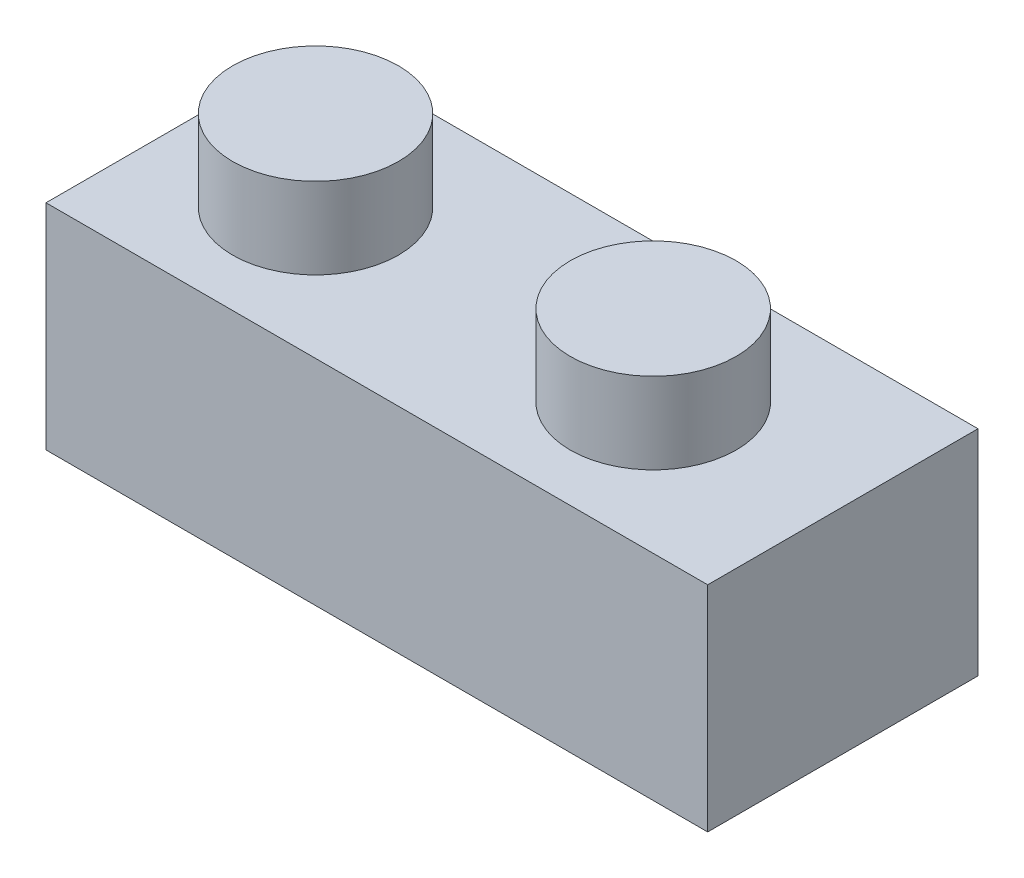
from build123d import *

# Parameters (mm, degrees)
ESQUISSE1_W             = 0.024479563
ESQUISSE1_H             = 0.007919518
BOSS_EXTRU_2_DEPTH      = 0.01
ENL_V_MAT_EXTRU_2_DEPTH = 0.007
ESQUISSE4_R             = 0.003068472
ESQUISSE4_R_2           = 0.003068475
BOSS_EXTRU_3_DEPTH      = 0.003
ESQUISSE5_R             = 0.001210602
BOSS_EXTRU_4_DEPTH      = 0.0065


with BuildPart() as part:
    # Esquisse1 → Boss.-Extru.2 (new body)
    with BuildSketch(Plane.XY):
        with Locations((0.012239782, 0.003959759)):
            Rectangle(ESQUISSE1_W, ESQUISSE1_H)
    extrude(amount=BOSS_EXTRU_2_DEPTH)

    # Esquisse3 → Enlèv. mat.-Extru.2 (cut)
    with BuildSketch(Plane(origin=(0, 0, 0), x_dir=(-1, 0, 0), z_dir=(0, -1, 0))):
        Polygon((-0.000784109, -0.009303073), (-0.023637888, -0.009504555), (-0.02371631, -0.000609239), (-0.000862531, -0.000407757), align=None)
    extrude(amount=-ENL_V_MAT_EXTRU_2_DEPTH, mode=Mode.SUBTRACT)

    # Esquisse4 → Boss.-Extru.3 (add)
    with BuildSketch(Plane(origin=(0, 0.007919518, 0), x_dir=(1, 0, 0), z_dir=(0, 1, 0))):
        with Locations((0.005130357, -0.005158307)):
            Circle(ESQUISSE4_R)
        with Locations((0.017622221, -0.005158307)):
            Circle(ESQUISSE4_R_2)
    extrude(amount=BOSS_EXTRU_3_DEPTH)

    # Esquisse5 → Boss.-Extru.4 (add)
    with BuildSketch(Plane(origin=(0, 0.007, 0), x_dir=(-1, 0, 0), z_dir=(0, -1, 0))):
        with Locations((-0.011667014, -0.004960674)):
            Circle(ESQUISSE5_R)
    extrude(amount=BOSS_EXTRU_4_DEPTH)


solid = part.part
